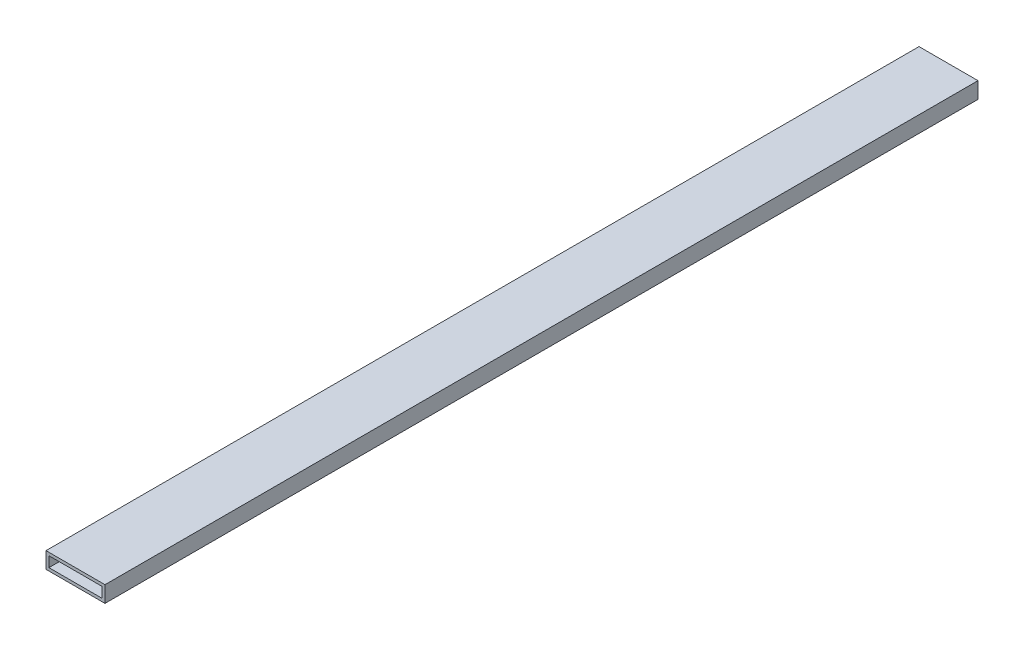
from build123d import *

# Parameters (mm, degrees)
SKETCH1_W           = 40
SKETCH1_H           = 11
SKETCH1_W_2         = 36
SKETCH1_H_2         = 7
BOSS_EXTRUDE1_DEPTH = 592


with BuildPart() as part:
    # Sketch1 → Boss-Extrude1 (new body)
    with BuildSketch(Plane.XY):
        Rectangle(SKETCH1_W, SKETCH1_H)
        Rectangle(SKETCH1_W_2, SKETCH1_H_2, mode=Mode.SUBTRACT)
    extrude(amount=BOSS_EXTRUDE1_DEPTH)


solid = part.part
